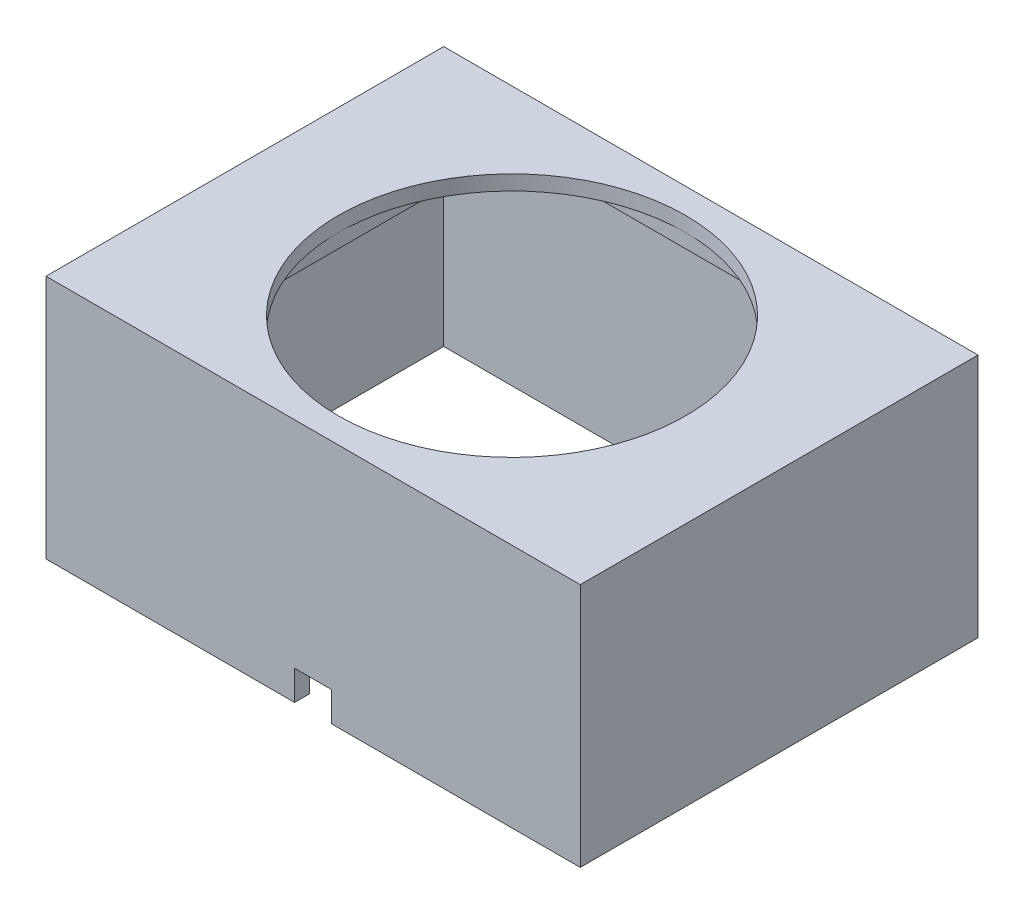
from build123d import *

# Parameters (mm, degrees)
SKETCH_190_W        = 36
SKETCH_190_H        = 26.8
EXTRUDE_1_DEPTH     = 16.5
SKETCH_353_W        = 34
SKETCH_353_H        = 24.8
CUT_EXTRUDE_1_DEPTH = 14.5
SKETCH_4_W          = 23.5
SKETCH_4_H          = 23.5
CUT_EXTRUDE_2_DEPTH = 1
SKETCH_5_R          = 11.7
CUT_EXTRUDE_3_DEPTH = 6
SKETCH_11_W         = 2.5
SKETCH_11_H         = 1
CUT_EXTRUDE_6_DEPTH = 2


with BuildPart() as part:
    # Sketch 190 → 凸台-拉伸1 (new body)
    with BuildSketch(Plane(origin=(0, 0, 0), x_dir=(1, 0, 0), z_dir=(0, 1, 0))):
        Rectangle(SKETCH_190_W, SKETCH_190_H)
    extrude(amount=EXTRUDE_1_DEPTH)

    # Sketch 353 → 切除-拉伸1 (cut)
    with BuildSketch(Plane(origin=(0, 0, 0), x_dir=(-1, 0, 0), z_dir=(0, -1, 0))):
        Rectangle(SKETCH_353_W, SKETCH_353_H)
    extrude(amount=-CUT_EXTRUDE_1_DEPTH, mode=Mode.SUBTRACT)

    # 草图4 → 切除-拉伸2 (cut)
    with BuildSketch(Plane.XZ.offset(-14.5)):
        Rectangle(SKETCH_4_W, SKETCH_4_H)
    extrude(amount=-CUT_EXTRUDE_2_DEPTH, mode=Mode.SUBTRACT)

    # 草图5 → 切除-拉伸3 (cut)
    with BuildSketch(Plane.XZ.offset(-15.5)):
        Circle(SKETCH_5_R)
    extrude(amount=-CUT_EXTRUDE_3_DEPTH, mode=Mode.SUBTRACT)

    # 草图11 → 切除-拉伸6 (cut)
    with BuildSketch(Plane(origin=(0, 0, 0), x_dir=(-1, 0, 0), z_dir=(0, -1, 0))):
        with Locations((0, -12.9)):
            Rectangle(SKETCH_11_W, SKETCH_11_H)
    extrude(amount=-CUT_EXTRUDE_6_DEPTH, mode=Mode.SUBTRACT)


solid = part.part
